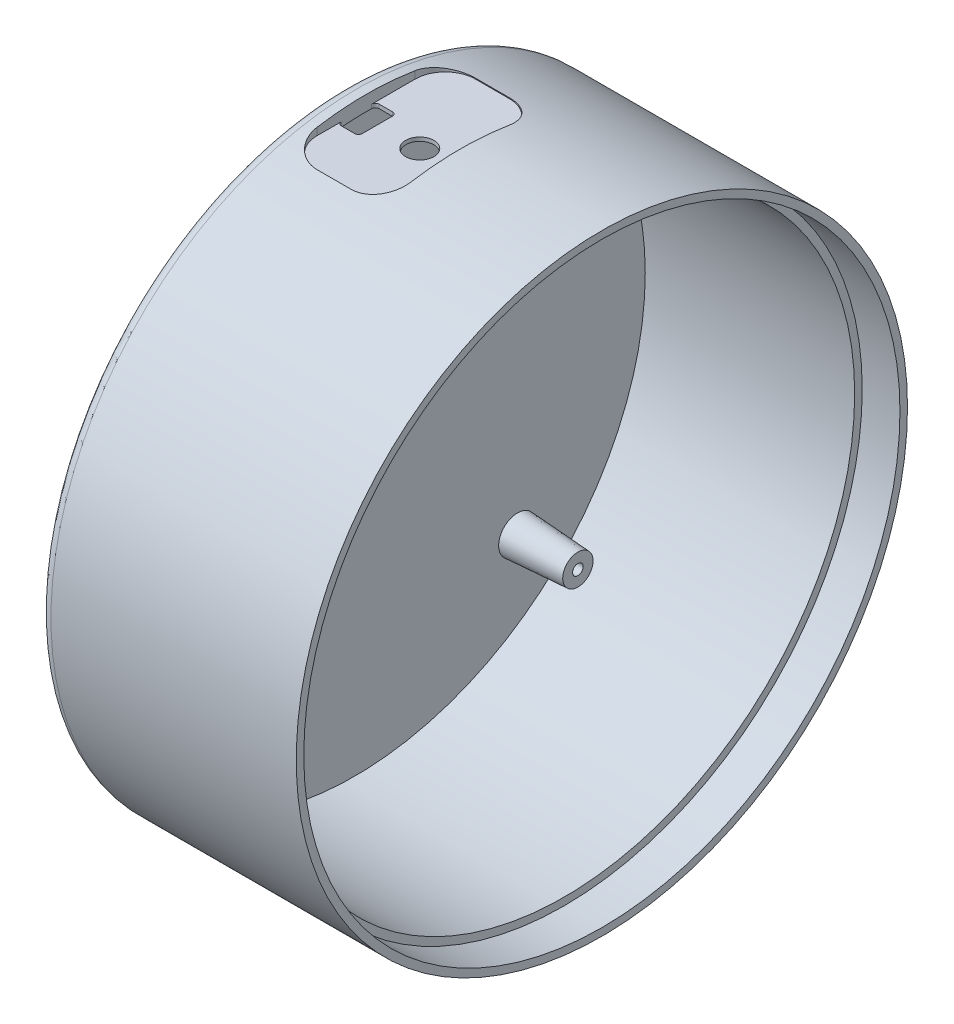
from build123d import *

# Parameters (mm, degrees)
SKETCH1_R           = 81
BOSS_EXTRUDE1_DEPTH = 2.5
SKETCH2_R           = 81
SKETCH2_R_2         = 77
BOSS_EXTRUDE2_DEPTH = 65.5
SKETCH4_R           = 5
BOSS_EXTRUDE3_DEPTH = 16
BOSS_EXTRUDE3_TAPER = 3.5
SKETCH6_R           = 1.4
CUT_EXTRUDE2_DEPTH  = 7
SKETCH7_R           = 79
CUT_EXTRUDE3_DEPTH  = 10
FILLET1_R           = 3
SKETCH8_R           = 3
BOSS_EXTRUDE4_DEPTH = 4
BOSS_EXTRUDE4_TAPER = 5
SKETCH9_R           = 1
CUT_EXTRUDE4_DEPTH  = 3
CUT_EXTRUDE5_DEPTH  = 3
CUT_EXTRUDE7_DEPTH  = 3
SKETCH15_R          = 3.75
CUT_EXTRUDE8_DEPTH  = 3


with BuildPart() as part:
    # Sketch1 → Boss-Extrude1 (new body)
    with BuildSketch(Plane(origin=(0, 0, 0), x_dir=(0, 0, -1), z_dir=(1, 0, 0))):
        Circle(SKETCH1_R)
    extrude(amount=BOSS_EXTRUDE1_DEPTH)

    # Sketch2 → Boss-Extrude2 (add)
    with BuildSketch(Plane(origin=(2.5, 0, 0), x_dir=(0, 0, -1), z_dir=(1, 0, 0))):
        Circle(SKETCH2_R)
        Circle(SKETCH2_R_2, mode=Mode.SUBTRACT)
    extrude(amount=BOSS_EXTRUDE2_DEPTH)

    # Sketch4 → Boss-Extrude3 (add)
    with BuildSketch(Plane(origin=(2.5, 0, 0), x_dir=(0, 0, -1), z_dir=(1, 0, 0))):
        with Locations((43.14, 43.135)):
            Circle(SKETCH4_R)
        with Locations((-43.14, 43.135)):
            Circle(SKETCH4_R)
        with Locations((43.14, -43.135)):
            Circle(SKETCH4_R)
        with Locations((-43.14, -43.135)):
            Circle(SKETCH4_R)
    extrude(amount=BOSS_EXTRUDE3_DEPTH, taper=BOSS_EXTRUDE3_TAPER)

    # Sketch6 → Cut-Extrude2 (cut)
    with BuildSketch(Plane(origin=(18.5, 0, 0), x_dir=(0, 0, -1), z_dir=(1, 0, 0))):
        with Locations((-43.14, 43.135)):
            Circle(SKETCH6_R)
        with Locations((43.14, 43.135)):
            Circle(SKETCH6_R)
        with Locations((-43.14, -43.135)):
            Circle(SKETCH6_R)
        with Locations((43.14, -43.135)):
            Circle(SKETCH6_R)
    extrude(amount=-CUT_EXTRUDE2_DEPTH, mode=Mode.SUBTRACT)

    # Sketch7 → Cut-Extrude3 (cut)
    with BuildSketch(Plane(origin=(68, 0, 0), x_dir=(0, 0, -1), z_dir=(1, 0, 0))):
        Circle(SKETCH7_R)
    extrude(amount=-CUT_EXTRUDE3_DEPTH, mode=Mode.SUBTRACT)

    # Fillet1
    fillet1_edges = [part.edges().sort_by_distance(p)[0] for p in [
        (0, 0, 81),
    ]]
    fillet(fillet1_edges, radius=FILLET1_R)

    # Sketch8 → Boss-Extrude4 (add)
    with BuildSketch(Plane(origin=(2.5, 0, 0), x_dir=(0, 0, -1), z_dir=(1, 0, 0))):
        with Locations((18.48, 71.045884469)):
            Circle(SKETCH8_R)
        with Locations((-18.48, 71.045884469)):
            Circle(SKETCH8_R)
        with Locations((18.48, 11.045884469)):
            Circle(SKETCH8_R)
        with Locations((-18.48, 11.045884469)):
            Circle(SKETCH8_R)
    extrude(amount=BOSS_EXTRUDE4_DEPTH, taper=BOSS_EXTRUDE4_TAPER)

    # Sketch9 → Cut-Extrude4 (cut)
    with BuildSketch(Plane(origin=(6.5, 0, 0), x_dir=(0, 0, -1), z_dir=(1, 0, 0))):
        with Locations((18.48, 71.045884469)):
            Circle(SKETCH9_R)
        with Locations((-18.48, 71.045884469)):
            Circle(SKETCH9_R)
        with Locations((-18.48, 11.045884469)):
            Circle(SKETCH9_R)
        with Locations((18.48, 11.045884469)):
            Circle(SKETCH9_R)
    extrude(amount=-CUT_EXTRUDE4_DEPTH, mode=Mode.SUBTRACT)

    # Sketch10 → Cut-Extrude5 (cut)
    with BuildSketch(Plane(origin=(0, 81, 0), x_dir=(1, 0, 0), z_dir=(0, 1, 0))):
        with BuildLine():
            Line((13.5, 21), (22.5, 21))
            ThreePointArc((22.5, 21), (28.156854249, 18.656854249), (30.5, 13))
            Line((30.5, 13), (30.5, -13))
            ThreePointArc((30.5, -13), (28.156854249, -18.656854249), (22.5, -21))
            Line((22.5, -21), (13.5, -21))
            ThreePointArc((13.5, -21), (7.843145751, -18.656854249), (5.5, -13))
            Line((5.5, -13), (5.5, 13))
            ThreePointArc((5.5, 13), (7.843145751, 18.656854249), (13.5, 21))
        make_face()
    extrude(amount=-CUT_EXTRUDE5_DEPTH, mode=Mode.SUBTRACT)

    # Sketch14 → Cut-Extrude7 (cut)
    with BuildSketch(Plane(origin=(0, 78, 0), x_dir=(1, 0, 0), z_dir=(0, 1, 0))):
        with BuildLine():
            Line((6.5, 2.5), (10, 2.5))
            ThreePointArc((10, 2.5), (10.707106781, 2.207106781), (11, 1.5))
            Line((11, 1.5), (11, -6.5))
            ThreePointArc((11, -6.5), (10.707106781, -7.207106781), (10, -7.5))
            Line((10, -7.5), (6.5, -7.5))
            ThreePointArc((6.5, -7.5), (5.792893219, -7.207106781), (5.5, -6.5))
            Line((5.5, -6.5), (5.5, 1.5))
            ThreePointArc((5.5, 1.5), (5.792893219, 2.207106781), (6.5, 2.5))
        make_face()
    extrude(amount=-CUT_EXTRUDE7_DEPTH, mode=Mode.SUBTRACT)

    # Sketch15 → Cut-Extrude8 (cut)
    with BuildSketch(Plane(origin=(0, 78, 0), x_dir=(1, 0, 0), z_dir=(0, 1, 0))):
        with Locations((22.046973968, -2.305883158)):
            Circle(SKETCH15_R)
    extrude(amount=-CUT_EXTRUDE8_DEPTH, mode=Mode.SUBTRACT)


solid = part.part
